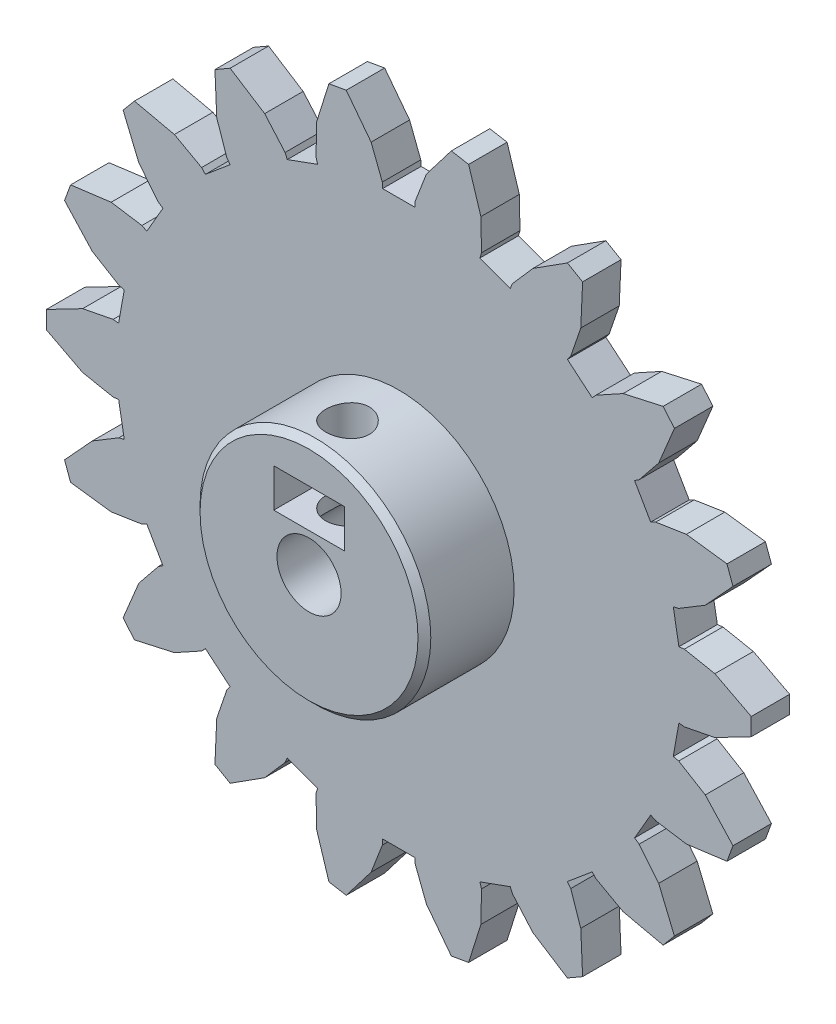
from build123d import *

# Parameters (mm, degrees)
BOSS_EXTRUDE1_DEPTH = 3
SKETCH2_R           = 9
BOSS_EXTRUDE2_DEPTH = 10
SKETCH3_R           = 2.5
CUT_EXTRUDE1_DEPTH  = 11
SKETCH4_R           = 1.7
CUT_EXTRUDE2_DEPTH  = 28.192254919
SKETCH6_W           = 5.5
SKETCH6_H           = 3
CUT_EXTRUDE3_DEPTH  = 6
CHAMFER1_SIZE       = 0.5


with BuildPart() as part:
    # Sketch1 → Boss-Extrude1 (new body)
    with BuildSketch(Plane.XY):
        Polygon((52.538753323, 31.842550454), (52.966828578, 31.892874255), (55.345645602, 31.426138186), (58.181047917, 29.953793943), (58.181047917, 28.58447352), (55.345645602, 27.112129278), (52.966828578, 26.645393209), (52.538753323, 26.695717009), (52.101175487, 24.214740941), (52.520827219, 24.115605549), (54.596406573, 22.863561667), (56.757515266, 20.510014449), (56.289051942, 19.223198182), (53.120822867, 18.809593755), (50.726022805, 19.184537369), (50.340928413, 19.378272292), (49.081325783, 17.196429655), (49.441582758, 16.959930445), (50.963818413, 15.073334341), (52.189727713, 12.122814362), (51.309387982, 11.073577892), (48.190619463, 11.768605458), (46.068603205, 12.939871673), (45.772925049, 13.253692509), (43.84291646, 11.634265293), (44.100798578, 11.288694958), (44.885889814, 8.995405743), (45.028653503, 5.803634881), (43.842700649, 5.118758859), (41.149630401, 6.838401289), (39.556121189, 8.664954435), (39.385711475, 9.061064382), (37.018340862, 8.199298953), (37.142314438, 7.786342725), (37.095662488, 5.362817582), (36.138217708, 2.31467442), (34.789414653, 2.076878813), (32.847095643, 4.613578553), (31.974531237, 6.875118271), (31.949693054, 7.30556898), (29.430487794, 7.30556898), (29.405650376, 6.875118271), (28.53308597, 4.613578553), (26.59076696, 2.076878813), (25.241963905, 2.31467442), (24.284519124, 5.362817582), (24.237867175, 7.786342725), (24.361839986, 8.199298953), (21.994469372, 9.061064382), (21.824060424, 8.664954435), (20.230551212, 6.838401289), (17.537480964, 5.118758859), (16.351527344, 5.803634881), (16.494291033, 8.995405743), (17.279383034, 11.288694958), (17.537264388, 11.634265293), (15.607256564, 13.253692509), (15.311577642, 12.939871673), (13.18956215, 11.768605458), (10.070792865, 11.073577892), (9.190453134, 12.122814362), (10.4163632, 15.073334341), (11.938598855, 16.959930445), (12.29885583, 17.196429655), (11.0392532, 19.378272292), (10.654158042, 19.184537369), (8.259357981, 18.809593755), (5.091129671, 19.223198182), (4.622666347, 20.510014449), (6.783774274, 22.863561667), (8.859354394, 24.115605549), (9.279006126, 24.214740941), (8.841427525, 26.695717009), (8.413353035, 26.645393209), (6.034535245, 27.112129278), (3.199133696, 28.58447352), (3.199133696, 29.953793943), (6.034535245, 31.426138186), (8.413353035, 31.892874255), (8.841427525, 31.842550454), (9.279006126, 34.323526523), (8.859354394, 34.422661915), (6.783774274, 35.674705796), (4.622666347, 38.028253015), (5.091129671, 39.315069282), (8.259357981, 39.728673709), (10.654158042, 39.353730095), (11.0392532, 39.159995172), (12.29885583, 41.341837809), (11.938598855, 41.578337019), (10.4163632, 43.464933122), (9.190453134, 46.415453101), (10.070792865, 47.464689572), (13.18956215, 46.769662005), (15.311577642, 45.598395791), (15.607256564, 45.284574954), (17.537264388, 46.904002171), (17.279383034, 47.249572505), (16.494291033, 49.542861721), (16.351527344, 52.734632582), (17.537480964, 53.419508605), (20.230551212, 51.699866175), (21.824060424, 49.873313028), (21.994469372, 49.477203082), (24.361839986, 50.338968511), (24.237867175, 50.751924739), (24.284519124, 53.175449881), (25.241963905, 56.223593043), (26.59076696, 56.461388651), (28.53308597, 53.92468891), (29.405650376, 51.663149193), (29.430487794, 51.232698484), (31.949693054, 51.232698484), (31.974531237, 51.663149193), (32.847095643, 53.92468891), (34.789414653, 56.461388651), (36.138217708, 56.223593043), (37.095662488, 53.175449881), (37.142314438, 50.751924739), (37.018340862, 50.338968511), (39.385711475, 49.477203082), (39.556121189, 49.873313028), (41.149630401, 51.699866175), (43.842700649, 53.419508605), (45.028653503, 52.734632582), (44.885889814, 49.542861721), (44.100798578, 47.249572505), (43.84291646, 46.904002171), (45.772925049, 45.284574954), (46.068603205, 45.598395791), (48.190619463, 46.769662005), (51.309387982, 47.464689572), (52.189727713, 46.415453101), (50.963818413, 43.464933122), (49.441582758, 41.578337019), (49.081325783, 41.341837809), (50.340928413, 39.159995172), (50.726022805, 39.353730095), (53.120822867, 39.728673709), (56.289051942, 39.315069282), (56.757515266, 38.028253015), (54.596406573, 35.674705796), (52.520827219, 34.422661915), (52.101175487, 34.323526523), align=None)
    extrude(amount=BOSS_EXTRUDE1_DEPTH)

    # Sketch2 → Boss-Extrude2 (add)
    with BuildSketch(Plane.XY):
        with Locations((30.690090806, 29.269133732)):
            Circle(SKETCH2_R)
    extrude(amount=BOSS_EXTRUDE2_DEPTH)

    # Sketch3 → Cut-Extrude1 (cut, through all)
    with BuildSketch(Plane.XY):
        with Locations((30.690090424, 29.269133732)):
            Circle(SKETCH3_R)
    extrude(amount=CUT_EXTRUDE1_DEPTH, mode=Mode.SUBTRACT)

    # Sketch4 → Cut-Extrude2 (cut, through all)
    with BuildSketch(Plane(origin=(0, 29.269133732, 0), x_dir=(1, 0, 0), z_dir=(0, 1, 0))):
        with Locations((30.690090424, -7)):
            Circle(SKETCH4_R)
    extrude(amount=CUT_EXTRUDE2_DEPTH, mode=Mode.SUBTRACT)

    # Sketch6 → Cut-Extrude3 (cut)
    with BuildSketch(Plane.XY.offset(10)):
        with Locations((30.690090806, 33.769133732)):
            Rectangle(SKETCH6_W, SKETCH6_H)
    extrude(amount=-CUT_EXTRUDE3_DEPTH, mode=Mode.SUBTRACT)

    # Chamfer1
    chamfer1_edges = [part.edges().sort_by_distance(p)[0] for p in [
        (21.690090806, 29.269133732, 10),
    ]]
    chamfer(chamfer1_edges, length=CHAMFER1_SIZE)


solid = part.part
